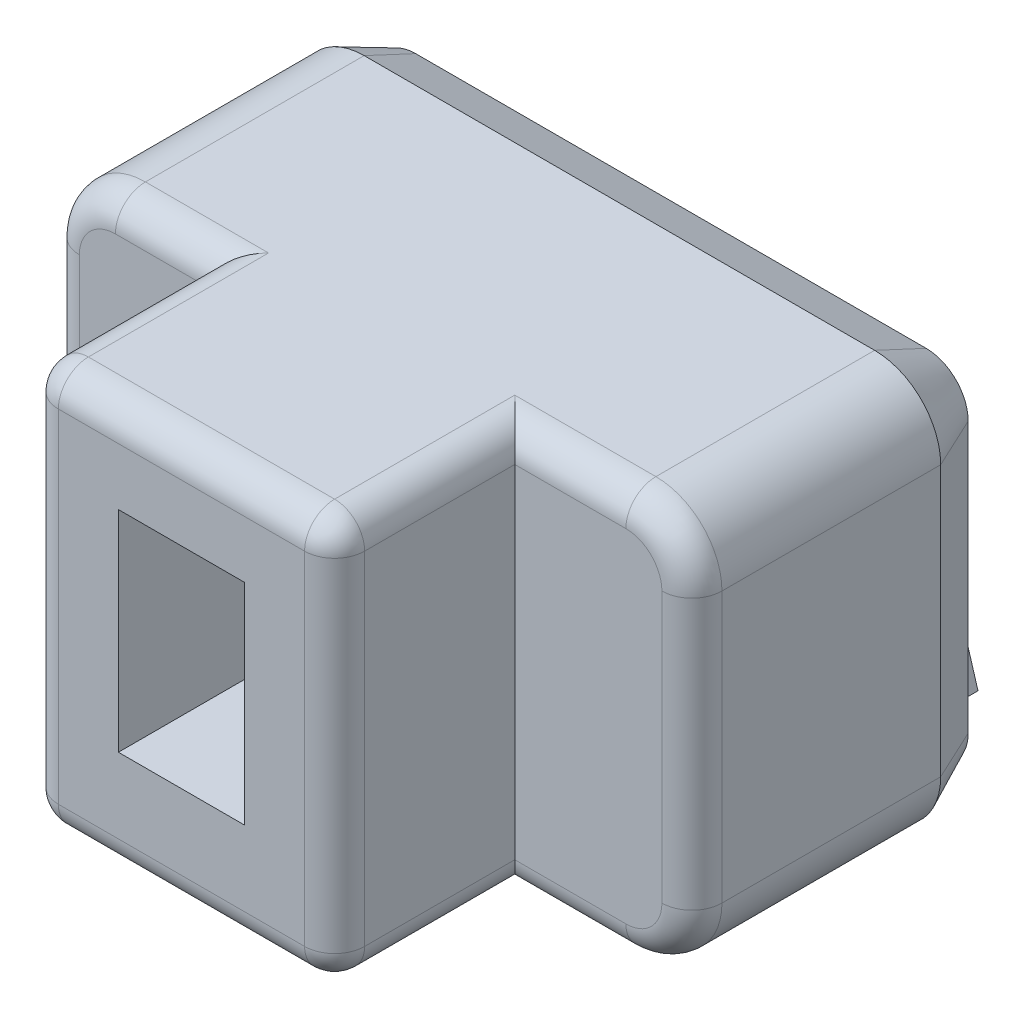
from build123d import *

# Parameters (mm, degrees)
BOSS_EXTRU_1_DEPTH      = 8
ESQUISSE3_W             = 2.1
ESQUISSE3_H             = 3.5
ENL_V_MAT_EXTRU_1_DEPTH = 3
ESQUISSE4_OUTSIDE_W     = 15.69
ESQUISSE4_OUTSIDE_H     = 11.69
ESQUISSE4_OUTSIDE_W_2   = 5.1
ESQUISSE4_OUTSIDE_H_2   = 6.7
ENL_V_MAT_EXTRU_2_DEPTH = 3
CONG_1_R                = 0.5
CHANFREIN1_SIZE         = 0.4
CHANFREIN1_SIZE2        = 0.857802768
ENL_V_MAT_EXTRU_3_DEPTH = 0.2
BOSS_EXTRU_2_DEPTH      = 0.2
BOSS_EXTRU_2_2_DEPTH    = 0.2
BOSS_EXTRU_2_3_DEPTH    = 0.2
BOSS_EXTRU_2_4_DEPTH    = 0.2


with BuildPart() as part:
    # Esquisse2 → Boss.-Extru.1 (new body)
    with BuildSketch(Plane.XY):
        with BuildLine():
            Line((1.1, 0), (9.6, 0))
            ThreePointArc((9.6, 0), (10.377817459, 0.322182541), (10.7, 1.1))
            Line((10.7, 1.1), (10.7, 5.6))
            ThreePointArc((10.7, 5.6), (10.377817459, 6.377817459), (9.6, 6.7))
            Line((9.6, 6.7), (1.1, 6.7))
            ThreePointArc((1.1, 6.7), (0.322182541, 6.377817459), (0, 5.6))
            Line((0, 5.6), (0, 1.1))
            ThreePointArc((0, 1.1), (0.322182541, 0.322182541), (1.1, 0))
        make_face()
    extrude(amount=BOSS_EXTRU_1_DEPTH)

    # Esquisse3 → Enlèv. mat.-Extru.1 (cut)
    with BuildSketch(Plane.XY.offset(8)):
        with Locations((5.2, 3.5)):
            Rectangle(ESQUISSE3_W, ESQUISSE3_H)
    extrude(amount=-ENL_V_MAT_EXTRU_1_DEPTH, mode=Mode.SUBTRACT)

    # Esquisse4 outside → Enlèv. mat.-Extru.2 (cut)
    with BuildSketch(Plane.XY.offset(8)):
        with Locations((5.35, 3.35)):
            Rectangle(ESQUISSE4_OUTSIDE_W, ESQUISSE4_OUTSIDE_H)
        with Locations((5.2, 3.35)):
            Rectangle(ESQUISSE4_OUTSIDE_W_2, ESQUISSE4_OUTSIDE_H_2, mode=Mode.SUBTRACT)
    extrude(amount=-ENL_V_MAT_EXTRU_2_DEPTH, mode=Mode.SUBTRACT)

    # Congé1
    cong_1_edges = [part.edges().sort_by_distance(p)[0] for p in [
        (8.675, 0, 5),
        (10.377817459, 0.322182541, 5),
        (10.7, 3.35, 5),
        (10.377817459, 6.377817459, 5),
        (1.875, 6.7, 5),
        (0.322182541, 6.377817459, 5),
        (1.875, 0, 5),
        (0.322182541, 0.322182541, 5),
        (7.75, 6.7, 6.5),
        (2.65, 6.7, 6.5),
        (7.75, 0, 6.5),
        (2.65, 0, 6.5),
        (2.65, 3.35, 8),
        (5.2, 6.7, 8),
        (7.75, 3.35, 8),
        (5.2, 0, 8),
        (8.675, 6.7, 5),
        (0, 3.35, 5),
    ]]
    fillet(cong_1_edges, radius=CONG_1_R)

    # Chanfrein1
    chanfrein1_edges = [part.edges().sort_by_distance(p)[0] for p in [
        (5.35, 0, 0),
        (10.377817459, 0.322182541, 0),
        (0.322182541, 0.322182541, 0),
        (10.7, 3.35, 0),
        (0, 3.35, 0),
        (10.377817459, 6.377817459, 0),
        (0.322182541, 6.377817459, 0),
        (5.35, 6.7, 0),
    ]]
    chanfrein1_side = [part.faces().sort_by_distance(p)[0] for p in [
        (5.35, 3.35, 0),
    ]]
    chamfer(chanfrein1_edges, length=CHANFREIN1_SIZE, length2=CHANFREIN1_SIZE2, reference=chanfrein1_side[0])

    # Esquisse5 → Enlèv. mat.-Extru.3 (cut)
    # profile 1 of 4: a face of its own
    with BuildSketch(Plane.XY):
        with BuildLine():
            add(Edge.make_bspline(
                [(1.632195637, 4.548933356), (1.682590452, 4.357036162), (1.784147589, 3.970319201), (1.894923296, 3.586141075), (1.950729738, 3.392600318)],
                knots=[0, 0, 0, 0, 0.992442604, 2, 2, 2, 2], degree=3))
            Line((1.950729738, 3.392600318), (2.476194751, 1.592998901))
            Line((2.476194751, 1.592998901), (2.823404671, 1.592998901))
            Line((2.823404671, 1.592998901), (1.774024689, 5.092998901))
            Line((1.774024689, 5.092998901), (1.479516275, 5.092998901))
            Line((1.479516275, 5.092998901), (0.42936127, 1.592998901))
            Line((0.42936127, 1.592998901), (0.777346213, 1.592998901))
            Line((0.777346213, 1.592998901), (1.302811226, 3.392600318))
            add(Edge.make_bspline(
                [(1.302811226, 3.392600318), (1.359193756, 3.586123032), (1.471092613, 3.970195371), (1.573074278, 4.357018822), (1.623670393, 4.548933356)],
                knots=[0, 0, 0, 0, 1.007740957, 2, 2, 2, 2], degree=3))
            Line((1.623670393, 4.548933356), (1.632195637, 4.548933356))
        make_face()
    # profile 2 of 4: a face of its own
    with BuildSketch(Plane.XY):
        with BuildLine():
            add(Edge.make_bspline(
                [(4.442425929, 3.544504658), (4.527003727, 3.700734463), (4.697671866, 4.015988), (4.860802198, 4.335207542), (4.943090234, 4.49623185)],
                knots=[0, 0, 0, 0, 0.991137522, 2, 2, 2, 2], degree=3))
            Line((4.943090234, 4.49623185), (4.955490588, 4.49623185))
            add(Edge.make_bspline(
                [(4.955490588, 4.49623185), (4.947675379, 4.324464032), (4.931897564, 3.977688809), (4.929549708, 3.630561968), (4.928364813, 3.455377112)],
                knots=[0, 0, 0, 0, 0.990657967, 2, 2, 2, 2], degree=3))
            Line((4.928364813, 3.455377112), (4.928364813, 1.592998901))
            Line((4.928364813, 1.592998901), (5.263949401, 1.592998901))
            Line((5.263949401, 1.592998901), (5.263949401, 5.092998901))
            Line((5.263949401, 5.092998901), (4.930689879, 5.092998901))
            Line((4.930689879, 5.092998901), (3.849533989, 3.141493144))
            add(Edge.make_bspline(
                [(3.849533989, 3.141493144), (3.803850976, 3.058165059), (3.714166924, 2.894576895), (3.586032196, 2.652217847), (3.464569757, 2.418559727), (3.387450477, 2.265030003), (3.349644707, 2.189765951)],
                knots=[0, 0, 0, 0, 1.06068051, 2.082308496, 3.059900396, 4, 4, 4, 4], degree=3))
            Line((3.349644707, 2.189765951), (3.337244352, 2.189765951))
            add(Edge.make_bspline(
                [(3.337244352, 2.189765951), (3.341389288, 2.272682265), (3.350025143, 2.445436025), (3.35800124, 2.714674155), (3.363799561, 3.004030352), (3.364175726, 3.203491585), (3.364370128, 3.30657286)],
                knots=[0, 0, 0, 0, 0.891652168, 1.857731716, 2.89287886, 4, 4, 4, 4], degree=3))
            Line((3.364370128, 3.30657286), (3.364370128, 5.092998901))
            Line((3.364370128, 5.092998901), (3.028785539, 5.092998901))
            Line((3.028785539, 5.092998901), (3.028785539, 1.592998901))
            Line((3.028785539, 1.592998901), (3.362045061, 1.592998901))
            Line((3.362045061, 1.592998901), (4.442425929, 3.544504658))
        make_face()
    # profile 3 of 4: a face of its own
    with BuildSketch(Plane.XY):
        Polygon((5.429029118, 5.092998901), (6.551261182, 1.592998901), (6.841119463, 1.592998901), (7.963351527, 5.092998901), (7.59909112, 5.092998901), (7.269706709, 4.038968786), (6.118798825, 4.038968786), (5.789414414, 5.092998901), align=None)
        with BuildLine():
            add(Edge.make_bspline(
                [(6.693090234, 2.137064446), (6.66306027, 2.243557177), (6.604319266, 2.451865453), (6.514977474, 2.756061775), (6.428522538, 3.045597969), (6.36984504, 3.233006242), (6.341230181, 3.32439837)],
                knots=[0, 0, 0, 0, 1.072120885, 2.097153972, 3.072051929, 4, 4, 4, 4], degree=3))
            Line((6.341230181, 3.32439837), (6.238152236, 3.654557803))
            Line((6.238152236, 3.654557803), (7.150353298, 3.654557803))
            Line((7.150353298, 3.654557803), (7.047275353, 3.32439837))
            add(Edge.make_bspline(
                [(7.047275353, 3.32439837), (7.018668804, 3.231711317), (6.96026651, 3.042484142), (6.874495303, 2.751759726), (6.787564337, 2.448750693), (6.730623833, 2.242260785), (6.701615477, 2.137064446)],
                knots=[0, 0, 0, 0, 0.941228557, 1.921584676, 2.941150745, 4, 4, 4, 4], degree=3))
            Line((6.701615477, 2.137064446), (6.693090234, 2.137064446))
        make_face(mode=Mode.SUBTRACT)
    # profile 4 of 4: a face of its own
    with BuildSketch(Plane.XY):
        with BuildLine():
            add(Edge.make_bspline(
                [(9.072408214, 4.548933356), (9.122803029, 4.357036162), (9.224360166, 3.970319201), (9.335135874, 3.586141075), (9.390942315, 3.392600318)],
                knots=[0, 0, 0, 0, 0.992442604, 2, 2, 2, 2], degree=3))
            Line((9.390942315, 3.392600318), (9.916407329, 1.592998901))
            Line((9.916407329, 1.592998901), (10.263617249, 1.592998901))
            Line((10.263617249, 1.592998901), (9.214237267, 5.092998901))
            Line((9.214237267, 5.092998901), (8.919728852, 5.092998901))
            Line((8.919728852, 5.092998901), (7.869573848, 1.592998901))
            Line((7.869573848, 1.592998901), (8.21755879, 1.592998901))
            Line((8.21755879, 1.592998901), (8.743023803, 3.392600318))
            add(Edge.make_bspline(
                [(8.743023803, 3.392600318), (8.799406334, 3.586123032), (8.911305191, 3.970195371), (9.013286856, 4.357018822), (9.063882971, 4.548933356)],
                knots=[0, 0, 0, 0, 1.007740957, 2, 2, 2, 2], degree=3))
            Line((9.063882971, 4.548933356), (9.072408214, 4.548933356))
        make_face()
    extrude(amount=ENL_V_MAT_EXTRU_3_DEPTH, mode=Mode.SUBTRACT)


with BuildPart() as body_2:
    # Esquisse5_4 → Boss.-Extru.2 (new body)
    with BuildSketch(Plane.XY):
        with BuildLine():
            add(Edge.make_bspline(
                [(1.632195637, 4.548933356), (1.682590452, 4.357036162), (1.784147589, 3.970319201), (1.894923296, 3.586141075), (1.950729738, 3.392600318)],
                knots=[0, 0, 0, 0, 0.992442604, 2, 2, 2, 2], degree=3))
            Line((1.950729738, 3.392600318), (2.476194751, 1.592998901))
            Line((2.476194751, 1.592998901), (2.823404671, 1.592998901))
            Line((2.823404671, 1.592998901), (1.774024689, 5.092998901))
            Line((1.774024689, 5.092998901), (1.479516275, 5.092998901))
            Line((1.479516275, 5.092998901), (0.42936127, 1.592998901))
            Line((0.42936127, 1.592998901), (0.777346213, 1.592998901))
            Line((0.777346213, 1.592998901), (1.302811226, 3.392600318))
            add(Edge.make_bspline(
                [(1.302811226, 3.392600318), (1.359193756, 3.586123032), (1.471092613, 3.970195371), (1.573074278, 4.357018822), (1.623670393, 4.548933356)],
                knots=[0, 0, 0, 0, 1.007740957, 2, 2, 2, 2], degree=3))
            Line((1.623670393, 4.548933356), (1.632195637, 4.548933356))
        make_face()
    extrude(amount=-BOSS_EXTRU_2_DEPTH)


with BuildPart() as body_3:
    # Esquisse5_4 → Boss.-Extru.2 2 (new body)
    with BuildSketch(Plane.XY):
        with BuildLine():
            add(Edge.make_bspline(
                [(4.442425929, 3.544504658), (4.527003727, 3.700734463), (4.697671866, 4.015988), (4.860802198, 4.335207542), (4.943090234, 4.49623185)],
                knots=[0, 0, 0, 0, 0.991137522, 2, 2, 2, 2], degree=3))
            Line((4.943090234, 4.49623185), (4.955490588, 4.49623185))
            add(Edge.make_bspline(
                [(4.955490588, 4.49623185), (4.947675379, 4.324464032), (4.931897564, 3.977688809), (4.929549708, 3.630561968), (4.928364813, 3.455377112)],
                knots=[0, 0, 0, 0, 0.990657967, 2, 2, 2, 2], degree=3))
            Line((4.928364813, 3.455377112), (4.928364813, 1.592998901))
            Line((4.928364813, 1.592998901), (5.263949401, 1.592998901))
            Line((5.263949401, 1.592998901), (5.263949401, 5.092998901))
            Line((5.263949401, 5.092998901), (4.930689879, 5.092998901))
            Line((4.930689879, 5.092998901), (3.849533989, 3.141493144))
            add(Edge.make_bspline(
                [(3.849533989, 3.141493144), (3.803850976, 3.058165059), (3.714166924, 2.894576895), (3.586032196, 2.652217847), (3.464569757, 2.418559727), (3.387450477, 2.265030003), (3.349644707, 2.189765951)],
                knots=[0, 0, 0, 0, 1.06068051, 2.082308496, 3.059900396, 4, 4, 4, 4], degree=3))
            Line((3.349644707, 2.189765951), (3.337244352, 2.189765951))
            add(Edge.make_bspline(
                [(3.337244352, 2.189765951), (3.341389288, 2.272682265), (3.350025143, 2.445436025), (3.35800124, 2.714674155), (3.363799561, 3.004030352), (3.364175726, 3.203491585), (3.364370128, 3.30657286)],
                knots=[0, 0, 0, 0, 0.891652168, 1.857731716, 2.89287886, 4, 4, 4, 4], degree=3))
            Line((3.364370128, 3.30657286), (3.364370128, 5.092998901))
            Line((3.364370128, 5.092998901), (3.028785539, 5.092998901))
            Line((3.028785539, 5.092998901), (3.028785539, 1.592998901))
            Line((3.028785539, 1.592998901), (3.362045061, 1.592998901))
            Line((3.362045061, 1.592998901), (4.442425929, 3.544504658))
        make_face()
    extrude(amount=-BOSS_EXTRU_2_2_DEPTH)


with BuildPart() as body_4:
    # Esquisse5_4 → Boss.-Extru.2 3 (new body)
    with BuildSketch(Plane.XY):
        Polygon((5.429029118, 5.092998901), (6.551261182, 1.592998901), (6.841119463, 1.592998901), (7.963351527, 5.092998901), (7.59909112, 5.092998901), (7.269706709, 4.038968786), (6.118798825, 4.038968786), (5.789414414, 5.092998901), align=None)
        with BuildLine():
            add(Edge.make_bspline(
                [(6.693090234, 2.137064446), (6.66306027, 2.243557177), (6.604319266, 2.451865453), (6.514977474, 2.756061775), (6.428522538, 3.045597969), (6.36984504, 3.233006242), (6.341230181, 3.32439837)],
                knots=[0, 0, 0, 0, 1.072120885, 2.097153972, 3.072051929, 4, 4, 4, 4], degree=3))
            Line((6.341230181, 3.32439837), (6.238152236, 3.654557803))
            Line((6.238152236, 3.654557803), (7.150353298, 3.654557803))
            Line((7.150353298, 3.654557803), (7.047275353, 3.32439837))
            add(Edge.make_bspline(
                [(7.047275353, 3.32439837), (7.018668804, 3.231711317), (6.96026651, 3.042484142), (6.874495303, 2.751759726), (6.787564337, 2.448750693), (6.730623833, 2.242260785), (6.701615477, 2.137064446)],
                knots=[0, 0, 0, 0, 0.941228557, 1.921584676, 2.941150745, 4, 4, 4, 4], degree=3))
            Line((6.701615477, 2.137064446), (6.693090234, 2.137064446))
        make_face(mode=Mode.SUBTRACT)
    extrude(amount=-BOSS_EXTRU_2_3_DEPTH)


with BuildPart() as body_5:
    # Esquisse5_4 → Boss.-Extru.2 4 (new body)
    with BuildSketch(Plane.XY):
        with BuildLine():
            add(Edge.make_bspline(
                [(9.072408214, 4.548933356), (9.122803029, 4.357036162), (9.224360166, 3.970319201), (9.335135874, 3.586141075), (9.390942315, 3.392600318)],
                knots=[0, 0, 0, 0, 0.992442604, 2, 2, 2, 2], degree=3))
            Line((9.390942315, 3.392600318), (9.916407329, 1.592998901))
            Line((9.916407329, 1.592998901), (10.263617249, 1.592998901))
            Line((10.263617249, 1.592998901), (9.214237267, 5.092998901))
            Line((9.214237267, 5.092998901), (8.919728852, 5.092998901))
            Line((8.919728852, 5.092998901), (7.869573848, 1.592998901))
            Line((7.869573848, 1.592998901), (8.21755879, 1.592998901))
            Line((8.21755879, 1.592998901), (8.743023803, 3.392600318))
            add(Edge.make_bspline(
                [(8.743023803, 3.392600318), (8.799406334, 3.586123032), (8.911305191, 3.970195371), (9.013286856, 4.357018822), (9.063882971, 4.548933356)],
                knots=[0, 0, 0, 0, 1.007740957, 2, 2, 2, 2], degree=3))
            Line((9.063882971, 4.548933356), (9.072408214, 4.548933356))
        make_face()
    extrude(amount=-BOSS_EXTRU_2_4_DEPTH)


solid = Compound([part.part, body_2.part, body_3.part, body_4.part, body_5.part])
